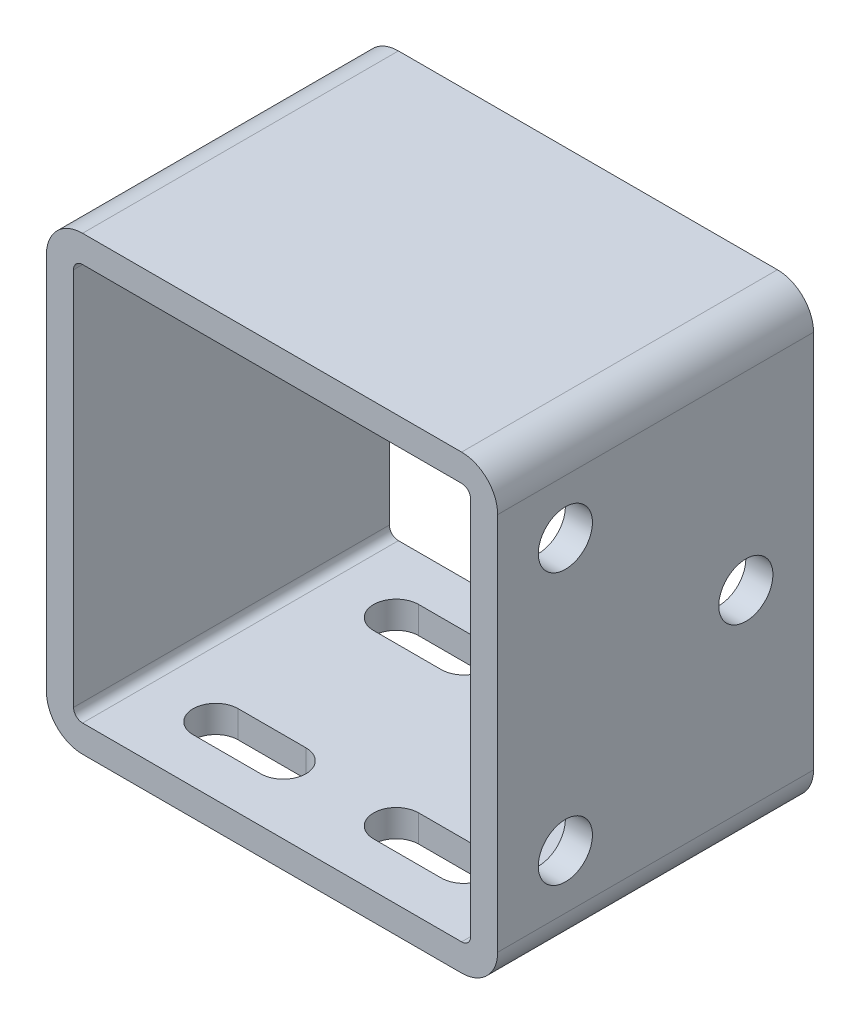
from build123d import *

# Parameters (mm, degrees)
EXTRUDE_1_DEPTH             = 70
CUT_EXTRUDE_1_REACH         = 102
SKETCH_2_R                  = 6
CUT_EXTRUDE_2_DEPTH         = 6
PATTERN_LINEAR_1_COUNT      = 2
PATTERN_LINEAR_1_PITCH      = 40
PATTERN_LINEAR_1_COUNT_DIR2 = 2
PATTERN_LINEAR_1_PITCH_DIR2 = 40


with BuildPart() as part:
    # 草图1 → 凸台-拉伸1 (new body)
    with BuildSketch(Plane.XY):
        with BuildLine():
            Line((8, 0), (92, 0))
            ThreePointArc((92, 0), (97.656854249, 2.343145751), (100, 8))
            Line((100, 8), (100, 92))
            ThreePointArc((100, 92), (97.656854249, 97.656854249), (92, 100))
            Line((92, 100), (8, 100))
            ThreePointArc((8, 100), (2.343145751, 97.656854249), (0, 92))
            Line((0, 92), (0, 8))
            ThreePointArc((0, 8), (2.343145751, 2.343145751), (8, 0))
        make_face()
        with BuildLine():
            Line((8, 94), (92, 94))
            ThreePointArc((92, 94), (93.414213562, 93.414213562), (94, 92))
            Line((94, 92), (94, 8))
            ThreePointArc((94, 8), (93.414213562, 6.585786438), (92, 6))
            Line((92, 6), (8, 6))
            ThreePointArc((8, 6), (6.585786438, 6.585786438), (6, 8))
            Line((6, 8), (6, 92))
            ThreePointArc((6, 92), (6.585786438, 93.414213562), (8, 94))
        make_face(mode=Mode.SUBTRACT)
    extrude(amount=EXTRUDE_1_DEPTH)

    # 草图2 → 切除-拉伸1 (cut, up to next)
    with BuildSketch(Plane(origin=(100, 0, 0), x_dir=(0, 0, -1), z_dir=(1, 0, 0)), mode=Mode.PRIVATE) as cut_extrude_1_sk1:
        with Locations((-55, 80)):
            Circle(SKETCH_2_R)
    cut_extrude_1_tool1 = extrude(cut_extrude_1_sk1.sketch, amount=-CUT_EXTRUDE_1_REACH, mode=Mode.PRIVATE) & part.part
    add(cut_extrude_1_tool1.solids().sort_by_distance((100, 80, 55))[0], mode=Mode.SUBTRACT)
    # 草图2 → 切除-拉伸1 (cut, up to next)
    with BuildSketch(Plane(origin=(100, 0, 0), x_dir=(0, 0, -1), z_dir=(1, 0, 0)), mode=Mode.PRIVATE) as cut_extrude_1_sk2:
        with Locations((-55, 20)):
            Circle(SKETCH_2_R)
    cut_extrude_1_tool2 = extrude(cut_extrude_1_sk2.sketch, amount=-CUT_EXTRUDE_1_REACH, mode=Mode.PRIVATE) & part.part
    add(cut_extrude_1_tool2.solids().sort_by_distance((100, 20, 55))[0], mode=Mode.SUBTRACT)
    # 草图2 → 切除-拉伸1 (cut, up to next)
    with BuildSketch(Plane(origin=(100, 0, 0), x_dir=(0, 0, -1), z_dir=(1, 0, 0)), mode=Mode.PRIVATE) as cut_extrude_1_sk3:
        with Locations((-15, 50)):
            Circle(SKETCH_2_R)
    cut_extrude_1_tool3 = extrude(cut_extrude_1_sk3.sketch, amount=-CUT_EXTRUDE_1_REACH, mode=Mode.PRIVATE) & part.part
    add(cut_extrude_1_tool3.solids().sort_by_distance((100, 50, 15))[0], mode=Mode.SUBTRACT)

    # 草图3 → 切除-拉伸2 (cut)
    with BuildSketch(Plane.XZ):
        with BuildLine():
            Line((77.5, 60), (62.5, 60))
            ThreePointArc((62.5, 60), (57.5, 55), (62.5, 50))
            Line((62.5, 50), (77.5, 50))
            ThreePointArc((77.5, 50), (82.5, 55), (77.5, 60))
        make_face()
    cut_extrude_2 = extrude(amount=-CUT_EXTRUDE_2_DEPTH, mode=Mode.SUBTRACT)

    # 阵列(线性)1: Cut-Extrude 2 2 × 2
    with Locations(*[(-j * PATTERN_LINEAR_1_PITCH_DIR2, 0, -i * PATTERN_LINEAR_1_PITCH) for i in range(PATTERN_LINEAR_1_COUNT) for j in range(PATTERN_LINEAR_1_COUNT_DIR2) if (i, j) != (0, 0)]):
        add(cut_extrude_2, mode=Mode.SUBTRACT)


solid = part.part
